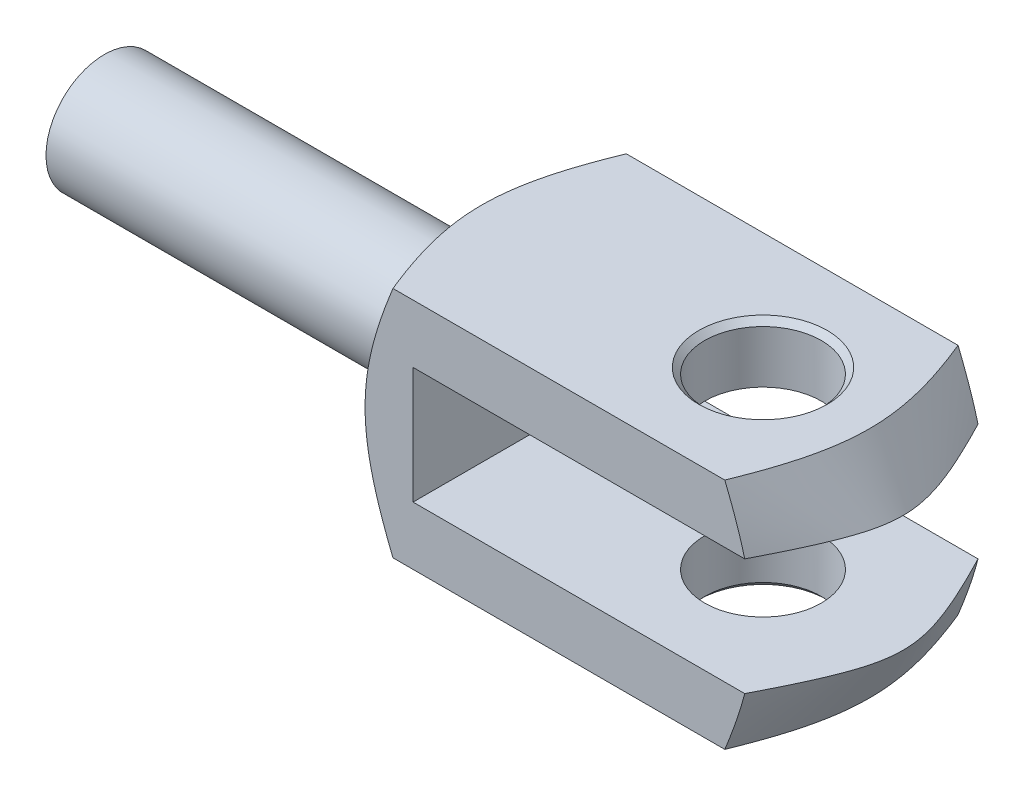
from build123d import *

# Parameters (mm, degrees)
SKETCH1_R                       = 5
EXTRUDE_L3_DEPTH                = 30
CLAW_EXTRUDE_DEPTH              = 10
THREAD_TO_CLAW_JOINING_FILLET_R = 0.8
SKETCH9_R                       = 5
CLEVIS_HOLE_DEPTH               = 1.0000001
CLEVIS_HOLE_DEPTH_BACK          = 21.0000001
CLEVIS_HOLE_CHAMFER_SIZE        = 0.5


with BuildPart() as part:
    # Sketch1 → L3 (new body)
    with BuildSketch(Plane(origin=(0, 0, 0), x_dir=(0, 0, -1), z_dir=(1, 0, 0))):
        Circle(SKETCH1_R)
    extrude(amount=EXTRUDE_L3_DEPTH)

    # Sketch6 → Claw Extrude (add, symmetric)
    with BuildSketch(Plane.XY):
        Polygon((30, -10), (30, 10), (69, 10), (69, 5), (37, 5), (37, -5), (69, -5), (69, -10), align=None)
    extrude(amount=CLAW_EXTRUDE_DEPTH, both=True)

    # Sketch8 → Claw Bevelling (revolve, cut)
    with BuildSketch(Plane(origin=(0, 0, 0), x_dir=(1, 0, 0), z_dir=(0, 1, 0))):
        Polygon((30, 5), (55.980762114, 50), (30, 50), align=None)
    revolve(axis=Axis((-49.725315437, 0, 0), (1, 0, 0)), mode=Mode.SUBTRACT)

    # Thread to Claw Joining Fillet
    thread_to_claw_joining_fillet_edges = [part.edges().sort_by_distance(p)[0] for p in [
        (30, 0, 5),
    ]]
    fillet(thread_to_claw_joining_fillet_edges, radius=THREAD_TO_CLAW_JOINING_FILLET_R)

    # Sketch11 → Claw Conic Taper (revolve, cut)
    with BuildSketch(Plane.XY):
        Polygon((11.264973081, 105), (69, 5), (69, 105), align=None)
    revolve(axis=Axis((56.222491899, 0, 0), (-1, 0, 0)), mode=Mode.SUBTRACT)

    # Sketch9 → Clevis Hole (cut, two sides)
    with BuildSketch(Plane(origin=(0, 10, 0), x_dir=(1, 0, 0), z_dir=(0, 1, 0))) as clevis_hole_sk:
        with Locations((57, 0)):
            Circle(SKETCH9_R)
    extrude(amount=CLEVIS_HOLE_DEPTH, mode=Mode.SUBTRACT)
    extrude(clevis_hole_sk.sketch, amount=-CLEVIS_HOLE_DEPTH_BACK, mode=Mode.SUBTRACT)

    # Clevis Hole Chamfer
    clevis_hole_chamfer_edges = [part.edges().sort_by_distance(p)[0] for p in [
        (52, -10, 0),
        (52, 10, 0),
    ]]
    chamfer(clevis_hole_chamfer_edges, length=CLEVIS_HOLE_CHAMFER_SIZE)

    # Sketch23 → Thread End Chamf (revolve, cut)
    with BuildSketch(Plane.XY):
        Polygon((0, 4.08), (0, 5), (0.531162248, 5), align=None)
    revolve(axis=Axis((-11.219306213, 0, 0), (1, 0, 0)), mode=Mode.SUBTRACT)


solid = part.part
